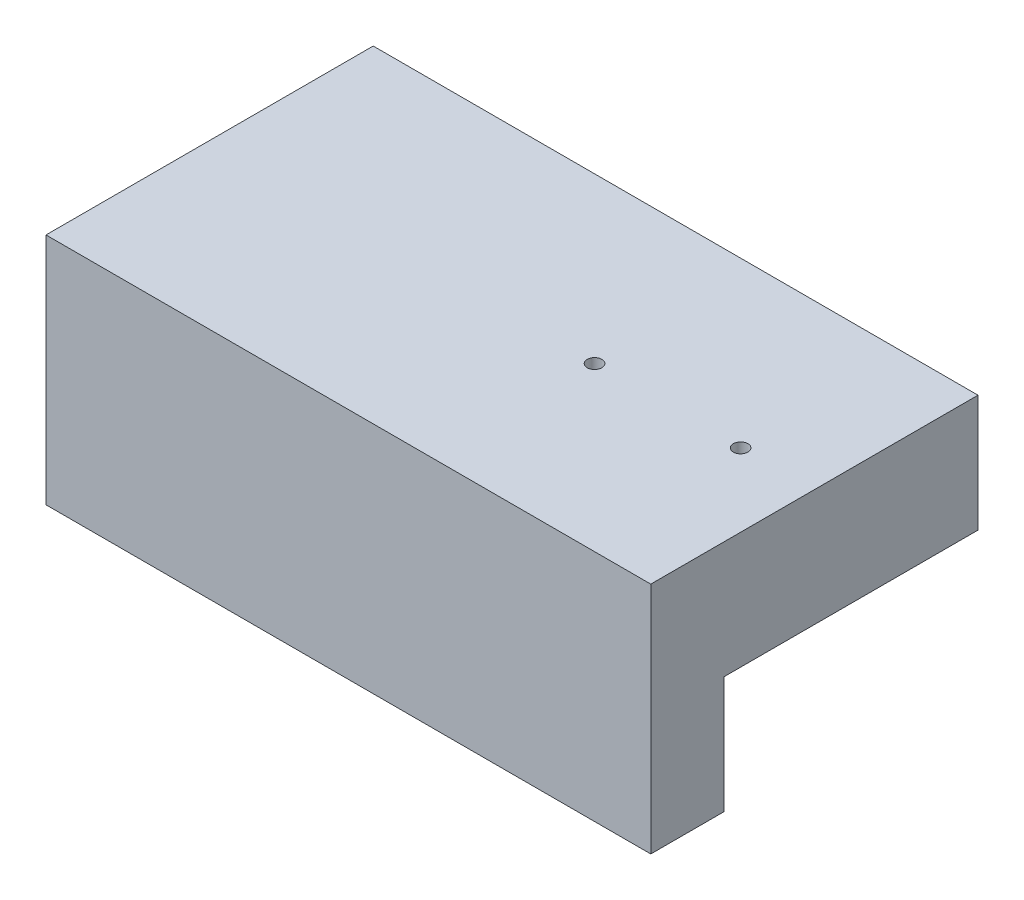
from build123d import *

# Parameters (mm, degrees)
SKETCH1_W           = 26.289
SKETCH1_H           = 14.224
BOSS_EXTRUDE2_DEPTH = 5.08
BOSS_EXTRUDE3_DEPTH = 5.08
CUT_EXTRUDE1_DEPTH  = 3.4925
CUT_EXTRUDE2_REACH  = 12.16
SKETCH4_R           = 0.3175


with BuildPart() as part:
    # Sketch1 → Boss-Extrude2 (new body)
    with BuildSketch(Plane(origin=(0, 26.595650985, 0), x_dir=(1, 0, 0), z_dir=(0, 1, 0))):
        with Locations((1.874973489, -26.877146351)):
            Rectangle(SKETCH1_W, SKETCH1_H)
    extrude(amount=BOSS_EXTRUDE2_DEPTH)

    # Sketch2 → Boss-Extrude3 (add)
    with BuildSketch(Plane.XZ.offset(-26.595650985)):
        Polygon((-11.269526511, 30.814146351), (-11.269526511, 33.989146351), (15.019473489, 33.989146351), (15.019473489, 30.814146351), (0.858973489, 30.814146351), (0.858973489, 32.401646351), (-4.221026511, 32.401646351), (-4.221026511, 30.814146351), align=None)
    extrude(amount=BOSS_EXTRUDE3_DEPTH)

    # Sketch3 → Cut-Extrude1 (cut)
    with BuildSketch(Plane.XZ.offset(-26.595650985)):
        Polygon((-4.221026511, 30.814146351), (-4.221026511, 32.401646351), (0.858973489, 32.401646351), (0.858973489, 30.814146351), (3.525973489, 30.814146351), (3.525973489, 21.352646351), (-6.888026511, 21.352646351), (-6.888026511, 30.814146351), align=None)
    extrude(amount=-CUT_EXTRUDE1_DEPTH, mode=Mode.SUBTRACT)

    # Sketch4 → Cut-Extrude2 (cut, up to next)
    with BuildSketch(Plane(origin=(0, 31.675650985, 0), x_dir=(1, 0, 0), z_dir=(0, 1, 0)), mode=Mode.PRIVATE) as cut_extrude2_sk1:
        with Locations((5.494473489, -26.908896351)):
            Circle(SKETCH4_R)
    cut_extrude2_tool1 = extrude(cut_extrude2_sk1.sketch, amount=-CUT_EXTRUDE2_REACH, mode=Mode.PRIVATE) & part.part
    add(cut_extrude2_tool1.solids().sort_by_distance((5.494473, 31.675651, 26.908896))[0], mode=Mode.SUBTRACT)
    # Sketch4 → Cut-Extrude2 (cut, up to next)
    with BuildSketch(Plane(origin=(0, 31.675650985, 0), x_dir=(1, 0, 0), z_dir=(0, 1, 0)), mode=Mode.PRIVATE) as cut_extrude2_sk2:
        with Locations((11.844473489, -26.908896351)):
            Circle(SKETCH4_R)
    cut_extrude2_tool2 = extrude(cut_extrude2_sk2.sketch, amount=-CUT_EXTRUDE2_REACH, mode=Mode.PRIVATE) & part.part
    add(cut_extrude2_tool2.solids().sort_by_distance((11.844473, 31.675651, 26.908896))[0], mode=Mode.SUBTRACT)


solid = part.part
